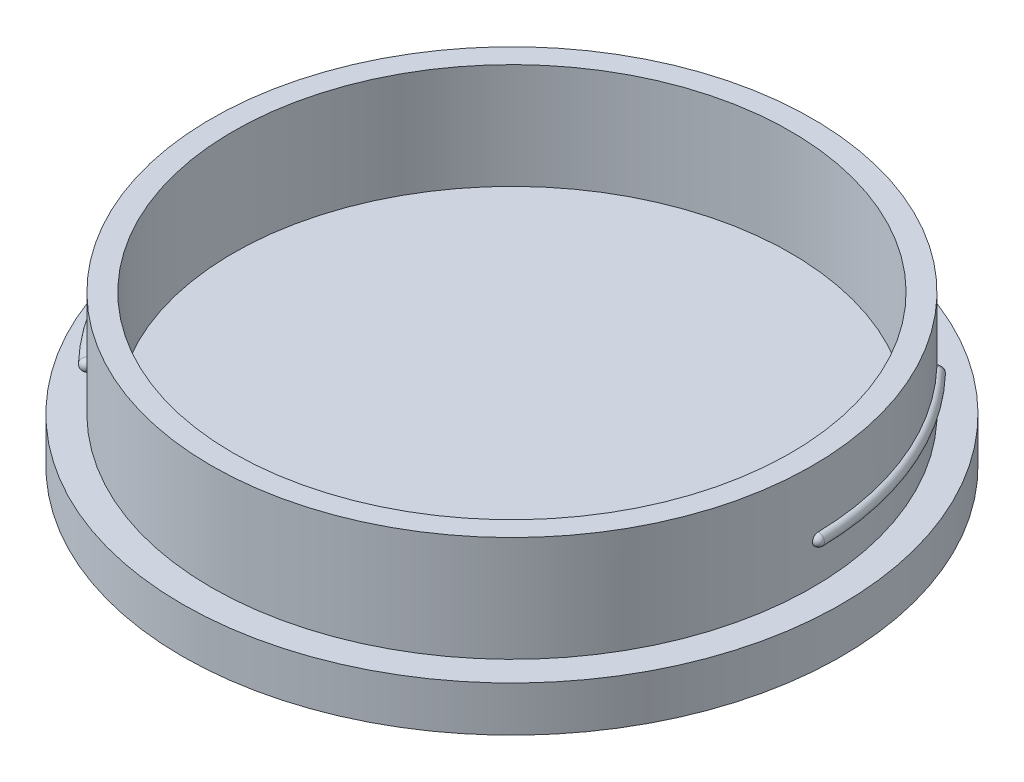
from build123d import *

# Parameters (mm, degrees)
SZKIC1_R                        = 21.875
DODANIE_WYCI_GNI_CIE1_DEPTH     = 3
DODANIE_WYCI_GNI_CIE2_START     = -3
SZKIC2_R                        = 19.95
SZKIC2_R_2                      = 18.5
DODANIE_WYCI_GNI_CIE2_DEPTH     = 10
DODANIE_WYCI_GNI_CIE3_DEPTH     = 1.4
SZKIC4_R                        = 0.4
OBR_T1_ANGLE                    = 45
ZAOKR_GLENIE2_R                 = 0.39
SZYK_KO_OWY5_COUNT              = 2
ZAOKR_GLENIE2_OF_SZYK_KO_OWY5_R = 0.39


with BuildPart() as part:
    # Szkic1 → Dodanie-wyciągnięcie1 (new body)
    with BuildSketch(Plane(origin=(0, 0, 0), x_dir=(1, 0, 0), z_dir=(0, 1, 0))):
        with Locations(Location((0, 0, 0), (0, 0, 270))):
            Circle(SZKIC1_R)
    extrude(amount=DODANIE_WYCI_GNI_CIE1_DEPTH)

    # Szkic2 → Dodanie-wyciągnięcie2 (add)
    with BuildSketch(Plane(origin=(0, 3, 0), x_dir=(1, 0, 0), z_dir=(0, 1, 0)).offset(DODANIE_WYCI_GNI_CIE2_START)):
        with Locations(Location((0, 0, 0), (0, 0, 270))):
            Circle(SZKIC2_R)
        with Locations(Location((0, 0, 0), (0, 0, 270))):
            Circle(SZKIC2_R_2, mode=Mode.SUBTRACT)
    extrude(amount=DODANIE_WYCI_GNI_CIE2_DEPTH)

    # Szkic3 → Dodanie-wyciągnięcie3 (add)
    with BuildSketch(Plane(origin=(0, 3, 0), x_dir=(1, 0, 0), z_dir=(0, 1, 0))):
        with BuildLine():
            Line((-2.25, 22.261584063), (-2.25, 19.822714244))
            ThreePointArc((-2.25, 19.822714244), (0, 19.95), (2.25, 19.822714244))
            Line((2.25, 19.822714244), (2.25, 22.261584063))
            ThreePointArc((2.25, 22.261584063), (0, 22.375), (-2.25, 22.261584063))
        make_face()
    extrude(amount=DODANIE_WYCI_GNI_CIE3_DEPTH)

    # Szkic4 → Obrót1 (revolve)
    with BuildSketch(Plane.XY):
        with Locations((-19.95, 5.6)):
            Circle(SZKIC4_R)
    obr_t1 = revolve(axis=Axis((0, -2.774596357, 0), (0, 1, 0)), revolution_arc=OBR_T1_ANGLE)

    # Zaokrąglenie2
    zaokr_glenie2_edges = [part.edges().sort_by_distance(p)[0] for p in [
        (-14.389622997, 5.6, 14.389622997),
        (-20.35, 5.6, 0),
    ]]
    fillet(zaokr_glenie2_edges, radius=ZAOKR_GLENIE2_R)

    # Szyk kołowy5: Obrót1 ×2 about axis
    szyk_ko_owy5_axis = Axis((0, 10, 0), (0, -1, 0))
    for i in range(1, SZYK_KO_OWY5_COUNT):
        add(obr_t1.rotate(szyk_ko_owy5_axis, i * 360 / SZYK_KO_OWY5_COUNT))

    # Zaokrąglenie2 of Szyk kołowy5
    zaokr_glenie2_of_szyk_ko_owy5_edges = [part.edges().sort_by_distance(p)[0] for p in [
        (14.389622997, 5.6, -14.389622997),
        (20.35, 5.6, 0),
    ]]
    fillet(zaokr_glenie2_of_szyk_ko_owy5_edges, radius=ZAOKR_GLENIE2_OF_SZYK_KO_OWY5_R)


solid = part.part
